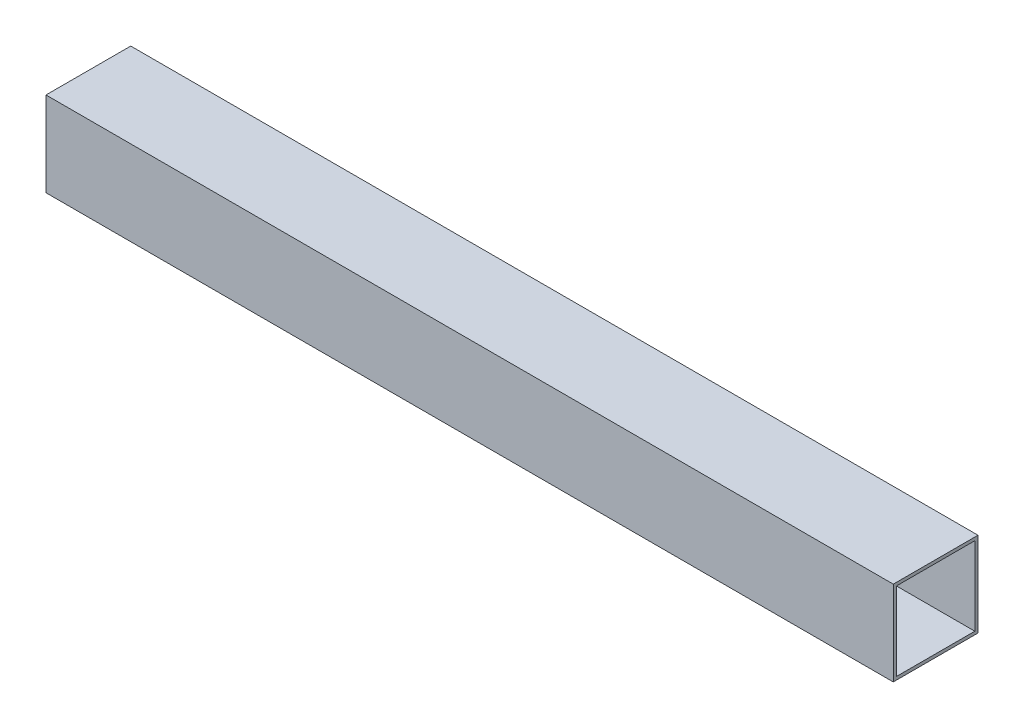
from build123d import *

# Parameters (mm, degrees)
ESBO_O1_W                = 40
ESBO_O1_H                = 40
RESSALTO_EXTRUS_O1_DEPTH = 400
ESBO_O2_W                = 37
ESBO_O2_H                = 37
CORTE_EXTRUS_O1_DEPTH    = 401


with BuildPart() as part:
    # Esboço1 → Ressalto-extrusão1 (new body)
    with BuildSketch(Plane(origin=(0, 0, 0), x_dir=(0, 0, -1), z_dir=(1, 0, 0))):
        Rectangle(ESBO_O1_W, ESBO_O1_H)
    extrude(amount=RESSALTO_EXTRUS_O1_DEPTH)

    # Esboço2 → Corte-extrusão1 (cut, through all)
    with BuildSketch(Plane.ZY):
        Rectangle(ESBO_O2_W, ESBO_O2_H)
    extrude(amount=-CORTE_EXTRUS_O1_DEPTH, mode=Mode.SUBTRACT)


solid = part.part
